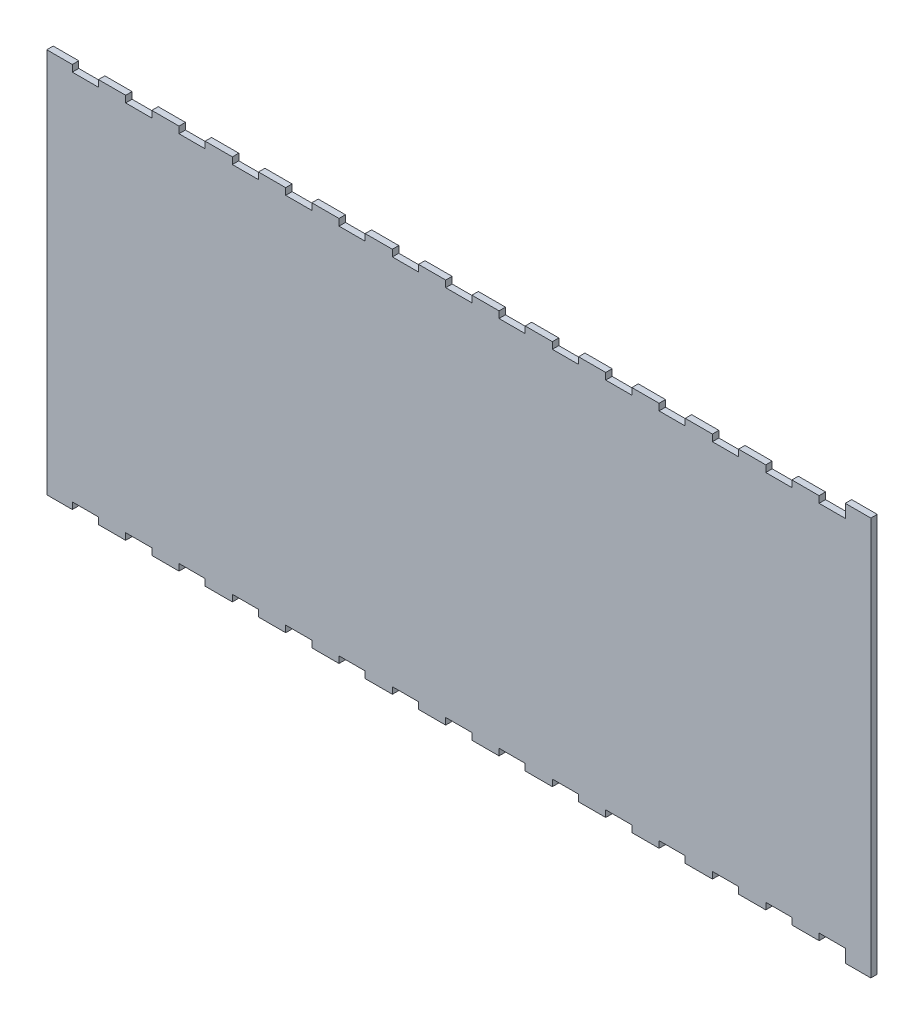
from build123d import *

# Parameters (mm, degrees)
BOSS_EXTRUDE1_DEPTH = 3.175


with BuildPart() as part:
    # Sketch1 → Boss-Extrude1 (new body)
    with BuildSketch(Plane.XY):
        Polygon((-12.6, 186.8186), (-25.5, 186.8186), (-25.5, 190.0936), (-38.907142857, 190.0936), (-38.907142857, 186.8186), (-51.807142857, 186.8186), (-51.807142857, 190.0936), (-65.214285714, 190.0936), (-65.214285714, 186.8186), (-78.114285714, 186.8186), (-78.114285714, 190.0936), (-91.521428571, 190.0936), (-91.521428571, 186.8186), (-104.421428571, 186.8186), (-104.421428571, 190.0936), (-117.828571429, 190.0936), (-117.828571429, 186.8186), (-130.728571429, 186.8186), (-130.728571429, 190.0936), (-144.135714286, 190.0936), (-144.135714286, 186.8186), (-157.035714286, 186.8186), (-157.035714286, 190.0936), (-170.442857143, 190.0936), (-170.442857143, 186.8186), (-183.342857143, 186.8186), (-183.342857143, 190.0936), (-196.75, 190.0936), (-196.75, 186.8186), (-209.65, 186.8186), (-209.65, 190.0936), (-223.057142857, 190.0936), (-223.057142857, 186.8186), (-235.957142857, 186.8186), (-235.957142857, 190.0936), (-249.364285714, 190.0936), (-249.364285714, 186.8186), (-262.264285714, 186.8186), (-262.264285714, 190.0936), (-275.671428571, 190.0936), (-275.671428571, 186.8186), (-288.571428571, 186.8186), (-288.571428571, 190.0936), (-301.978571429, 190.0936), (-301.978571429, 186.8186), (-314.878571429, 186.8186), (-314.878571429, 190.0936), (-328.285714286, 190.0936), (-328.285714286, 186.8186), (-341.185714286, 186.8186), (-341.185714286, 190.0936), (-354.592857143, 190.0936), (-354.592857143, 186.8186), (-367.492857143, 186.8186), (-367.492857143, 190.0936), (-380.9, 190.0936), (-380.9, 186.8186), (-393.8, 186.8186), (-393.8, 190.0936), (-406.4, 190.0936), (-406.4, 0), (-393.8, 0), (-393.8, 3.275), (-380.9, 3.275), (-380.9, 0), (-367.492857143, 0), (-367.492857143, 3.275), (-354.592857143, 3.275), (-354.592857143, 0), (-341.185714286, 0), (-341.185714286, 3.275), (-328.285714286, 3.275), (-328.285714286, 0), (-314.878571429, 0), (-314.878571429, 3.275), (-301.978571429, 3.275), (-301.978571429, 0), (-288.571428571, 0), (-288.571428571, 3.275), (-275.671428571, 3.275), (-275.671428571, 0), (-262.264285714, 0), (-262.264285714, 3.275), (-249.364285714, 3.275), (-249.364285714, 0), (-235.957142857, 0), (-235.957142857, 3.275), (-223.057142857, 3.275), (-223.057142857, 0), (-209.65, 0), (-209.65, 3.275), (-196.75, 3.275), (-196.75, 0), (-183.342857143, 0), (-183.342857143, 3.275), (-170.442857143, 3.275), (-170.442857143, 0), (-157.035714286, 0), (-157.035714286, 3.275), (-144.135714286, 3.275), (-144.135714286, 0), (-130.728571429, 0), (-130.728571429, 3.275), (-117.828571429, 3.275), (-117.828571429, 0), (-104.421428571, 0), (-104.421428571, 3.275), (-91.521428571, 3.275), (-91.521428571, 0), (-78.114285714, 0), (-78.114285714, 3.275), (-65.214285714, 3.275), (-65.214285714, 0), (-51.807142857, 0), (-51.807142857, 3.275), (-38.907142857, 3.275), (-38.907142857, 0), (-25.5, 0), (-25.5, 3.275), (-12.6, 3.275), (-12.6000002, -3.175), (0, -3.175), (0, 193.2686), (-12.6000002, 193.2686), align=None)
    extrude(amount=BOSS_EXTRUDE1_DEPTH)


solid = part.part
